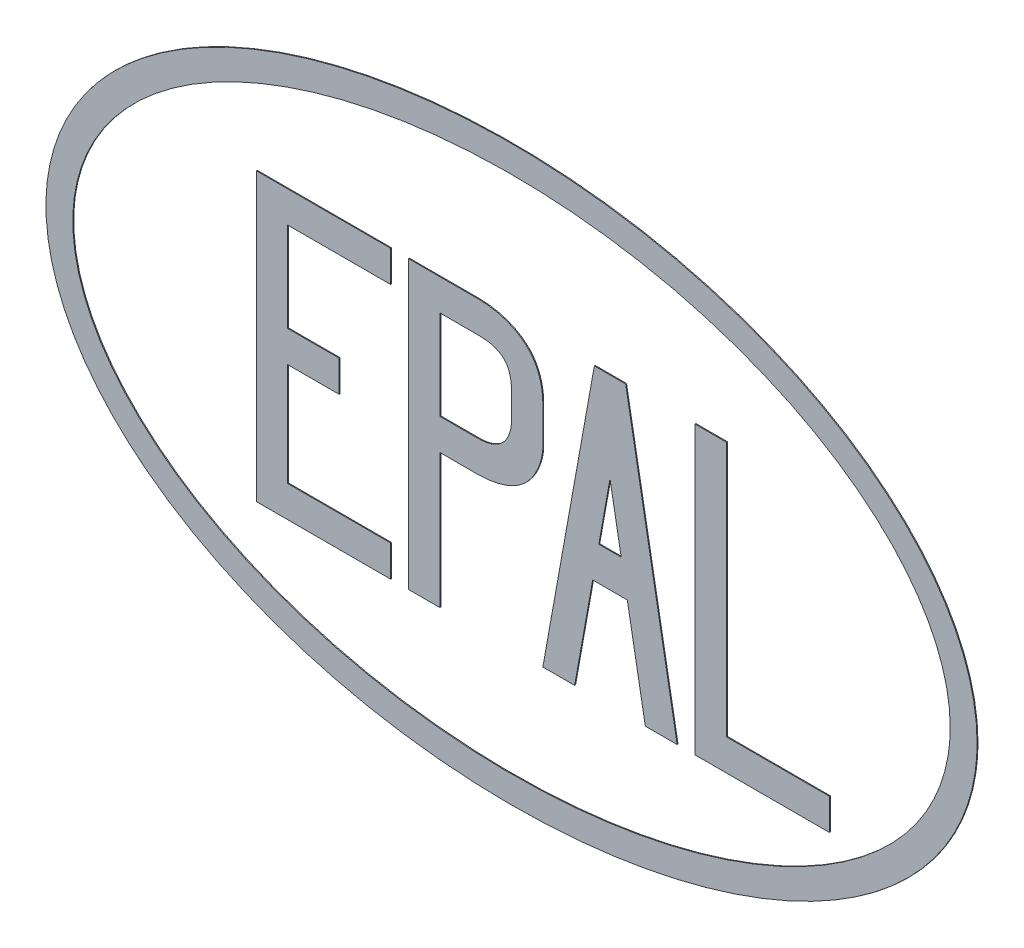
from build123d import *

# Parameters (mm, degrees)
BOSS_EXTRUDE2_DEPTH   = 0.1
BOSS_EXTRUDE2_2_DEPTH = 0.1
BOSS_EXTRUDE2_3_DEPTH = 0.1
BOSS_EXTRUDE2_4_DEPTH = 0.1
BOSS_EXTRUDE2_5_DEPTH = 0.1


with BuildPart() as part:
    # Sketch2 → Boss-Extrude2 (new body)
    with BuildSketch(Plane.XY):
        Polygon((-28.5, 15.1), (-28.5, -16.9), (-13.5, -16.9), (-13.5, -13.4), (-25, -13.4), (-25, -1.9), (-19.25, -1.9), (-19.25, 1.6), (-25, 1.6), (-25, 11.6), (-13.5, 11.6), (-13.5, 15.1), align=None)
    extrude(amount=BOSS_EXTRUDE2_DEPTH)


with BuildPart() as body_2:
    # Sketch2 → Boss-Extrude2 2 (new body)
    with BuildSketch(Plane.XY):
        with BuildLine():
            Line((-3.727187149, 15.1), (-11.5, 15.1))
            Line((-11.5, 15.1), (-11.5, -16.9))
            Line((-11.5, -16.9), (-8, -16.9))
            Line((-8, -16.9), (-8, -1.9))
            Line((-8, -1.9), (-3.727187149, -1.9))
            add(Edge.make_bspline(
                [(-3.727187149, -1.9), (-1.800593694, -1.9), (2.092379735, -0.898729508), (3.5, 3.146204469), (3.5, 4.402607436)],
                knots=[0, 0, 0, 0, 0.575012413, 1, 1, 1, 1], degree=3))
            Line((3.5, 4.402607436), (3.5, 8.576622723))
            add(Edge.make_bspline(
                [(-3.727187149, 15.1), (-1.171981894, 15.1), (2.856293535, 13.404615826), (3.5, 9.811349168), (3.5, 8.576622723)],
                knots=[0, 0, 0, 0, 0.562070833, 1, 1, 1, 1], degree=3))
        make_face()
        with BuildLine():
            Line((-8, 11.6), (-3.727187149, 11.6))
            add(Edge.make_bspline(
                [(-3.727187149, 11.6), (-1.090192408, 11.6), (0, 10.538373851), (0, 8.060268689)],
                knots=[0, 0, 0, 0, 1, 1, 1, 1], degree=3))
            Line((0, 8.060268689), (0, 5.139731311))
            add(Edge.make_bspline(
                [(-3.727187149, 1.6), (-0.42769757, 1.6), (0, 4.184998685), (0, 5.139731311)],
                knots=[0, 0, 0, 0, 1, 1, 1, 1], degree=3))
            Line((-3.727187149, 1.6), (-8, 1.6))
            Line((-8, 1.6), (-8, 11.6))
        make_face(mode=Mode.SUBTRACT)
    extrude(amount=BOSS_EXTRUDE2_2_DEPTH)


with BuildPart() as body_3:
    # Sketch2 → Boss-Extrude2 3 (new body)
    with BuildSketch(Plane.XY):
        Polygon((20.5, -16.9), (35.5, -16.9), (35.5, -13.4), (24, -13.4), (24, 15.1), (20.5, 15.1), align=None)
    extrude(amount=BOSS_EXTRUDE2_3_DEPTH)


with BuildPart() as body_4:
    # Sketch2 → Boss-Extrude2 4 (new body)
    with BuildSketch(Plane.XY):
        Polygon((7.056054425, -16.9), (9.068920287, -5.697963896), (12.931079713, -5.697963896), (14.943945575, -16.9), (18.5, -16.9), (12.75, 15.1), (9.25, 15.1), (3.5, -16.9), align=None)
        Polygon((12.248633075, -1.9), (9.751366925, -1.9), (11, 5.048914506), align=None, mode=Mode.SUBTRACT)
    extrude(amount=BOSS_EXTRUDE2_4_DEPTH)


with BuildPart() as body_5:
    # Sketch2 → Boss-Extrude2 5 (new body)
    with BuildSketch(Plane.XY):
        with BuildLine():
            add(Edge.make_bspline(
                [(52, 0), (52, 2.228948685), (51.252049299, 6.686846055), (46.957076028, 15.014779342), (37.045073505, 23.70283763), (19.937399208, 30.438442012), (0, 32.780778994), (-19.937399208, 30.438442012), (-37.045073505, 23.70283763), (-46.957076028, 15.014779342), (-51.252049299, 6.686846055), (-52.373975351, 0), (-51.252049299, -6.686846055), (-46.957076028, -15.014779342), (-37.045073505, -23.70283763), (-19.937399208, -30.438442012), (0, -32.780778994), (19.937399208, -30.438442012), (37.045073505, -23.70283763), (46.957076028, -15.014779342), (51.252049299, -6.686846055), (52, -2.228948685), (52, 0)],
                knots=[0, 0, 0, 0, 0.196349541, 0.392699082, 0.785398163, 1.178097245, 1.570796327, 1.963495408, 2.35619449, 2.748893572, 2.945243113, 3.141592654, 3.337942194, 3.534291735, 3.926990817, 4.319689899, 4.71238898, 5.105088062, 5.497787144, 5.890486225, 6.086835766, 6.283185307, 6.283185307, 6.283185307, 6.283185307], degree=3))
        make_face()
        with BuildLine():
            add(Edge.make_bspline(
                [(49, 0), (49, 3.795670439), (46.448408259, 11.387011317), (35.55056883, 21.03970762), (19.239984052, 27.489984223), (0, 29.755007889), (-19.239984052, 27.489984223), (-35.55056883, 21.03970762), (-46.448408259, 11.387011317), (-50.27579587, 0), (-46.448408259, -11.387011317), (-35.55056883, -21.03970762), (-19.239984052, -27.489984223), (0, -29.755007889), (19.239984052, -27.489984223), (35.55056883, -21.03970762), (46.448408259, -11.387011317), (49, -3.795670439), (49, 0)],
                knots=[0, 0, 0, 0, 0.392699082, 0.785398163, 1.178097245, 1.570796327, 1.963495408, 2.35619449, 2.748893572, 3.141592654, 3.534291735, 3.926990817, 4.319689899, 4.71238898, 5.105088062, 5.497787144, 5.890486225, 6.283185307, 6.283185307, 6.283185307, 6.283185307], degree=3))
        make_face(mode=Mode.SUBTRACT)
    extrude(amount=BOSS_EXTRUDE2_5_DEPTH)


solid = Compound([part.part, body_2.part, body_3.part, body_4.part, body_5.part])
